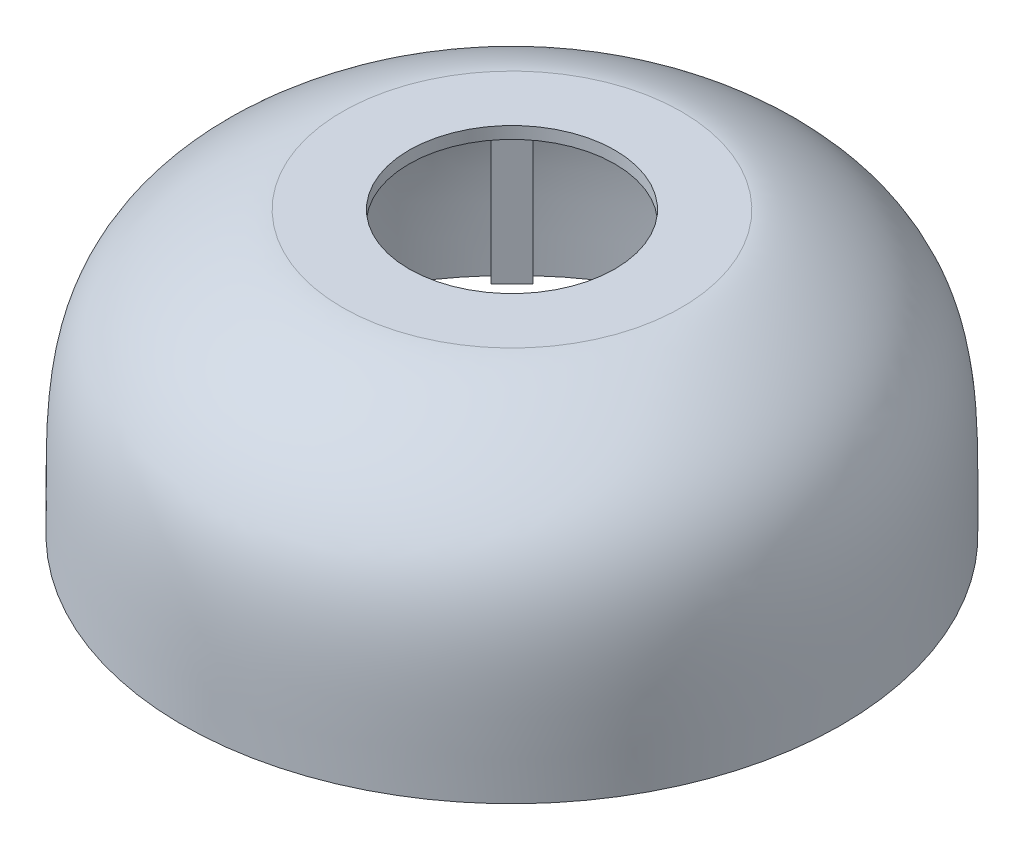
from build123d import *

# Parameters (mm, degrees)
AUFSATZ_LINEAR_AUSTRAGEN3_REACH = 92.88
SKIZZE2_R                       = 1.25
SKIZZE3_R                       = 53
SCHNITT_LINEAR_AUSTRAGEN1_DEPTH = 3
SCHNITT_LINEAR_AUSTRAGEN2_REACH = 92.88
SKIZZE4_W                       = 14
SKIZZE4_H                       = 11


with BuildPart() as part:
    # Skizze1 → Rotation1 (revolve)
    with BuildSketch(Plane.XY, mode=Mode.PRIVATE) as rotation1_sk:
        with BuildLine():
            Line((55, 0), (53, 0))
            add(Edge.make_bspline(
                [(53, 0), (53.048273889, 17.0063194), (53.749722024, 34.340834234), (31.815546139, 44.555146008), (28.310782841, 45)],
                knots=[0, 0, 0, 0, 0.631184982, 1, 1, 1, 1], degree=3))
            Line((28.310782841, 45), (17.182197797, 45))
            Line((17.182197797, 45), (17.182197797, 47))
            Line((17.182197797, 47), (28.310782841, 47))
            add(Edge.make_bspline(
                [(55, 0), (54.936392328, 18.162630291), (56.396449466, 34.368648063), (32.689382739, 46.685149183), (28.310782841, 47)],
                knots=[0, 0, 0, 0, 0.647187366, 1, 1, 1, 1], degree=3))
        make_face()
    revolve(rotation1_sk.sketch.rotate(Axis((0, -12.15098687, 0), (0, 1, 0)), 90), axis=Axis((0, -12.15098687, 0), (0, 1, 0)))

    # Skizze2 → Aufsatz-Linear austragen3 (add, up to next)
    with BuildSketch(Plane.XZ, mode=Mode.PRIVATE) as aufsatz_linear_austragen3_sk1:
        Polygon((31.466251763, 35.001785669), (36.213171094, 39.748705), (39.748705, 36.213171094), (35.001785669, 31.466251763), align=None)
        with Locations(Location((35.355339059, 35.355339059, 0), (0, 0, 270))):
            Circle(SKIZZE2_R, mode=Mode.SUBTRACT)
    aufsatz_linear_austragen3_tool1 = extrude(aufsatz_linear_austragen3_sk1.sketch, amount=-AUFSATZ_LINEAR_AUSTRAGEN3_REACH, mode=Mode.PRIVATE) - part.part
    # Skizze2 → Aufsatz-Linear austragen3 (add, up to next)
    with BuildSketch(Plane.XZ, mode=Mode.PRIVATE) as aufsatz_linear_austragen3_sk2:
        Polygon((-31.466251763, -35.001785669), (-36.213171094, -39.748705), (-39.748705, -36.213171094), (-35.001785669, -31.466251763), align=None)
        with Locations(Location((-35.355339059, -35.355339059, 0), (0, 0, 270))):
            Circle(SKIZZE2_R, mode=Mode.SUBTRACT)
    aufsatz_linear_austragen3_tool2 = extrude(aufsatz_linear_austragen3_sk2.sketch, amount=-AUFSATZ_LINEAR_AUSTRAGEN3_REACH, mode=Mode.PRIVATE) - part.part
    add(aufsatz_linear_austragen3_tool1.solids().sort_by_distance((33.922536, 0, 37.292421))[0])
    add(aufsatz_linear_austragen3_tool2.solids().sort_by_distance((-33.922536, 0, -37.292421))[0])

    # Skizze3 → Schnitt-Linear austragen1 (cut)
    with BuildSketch(Plane.XZ):
        Circle(SKIZZE3_R)
    extrude(amount=-SCHNITT_LINEAR_AUSTRAGEN1_DEPTH, mode=Mode.SUBTRACT)

    # Skizze4 → Schnitt-Linear austragen2 (cut, up to next)
    with BuildSketch(Plane(origin=(0, 0, 0), x_dir=(0, 0, -1), z_dir=(1, 0, 0)), mode=Mode.PRIVATE) as schnitt_linear_austragen2_sk1:
        with Locations((0.5, 5.5)):
            Rectangle(SKIZZE4_W, SKIZZE4_H)
    schnitt_linear_austragen2_tool1 = extrude(schnitt_linear_austragen2_sk1.sketch, amount=-SCHNITT_LINEAR_AUSTRAGEN2_REACH, mode=Mode.PRIVATE) & part.part
    add(schnitt_linear_austragen2_tool1.solids().sort_by_distance((0, 5.5, -0.5))[0], mode=Mode.SUBTRACT)


solid = part.part
